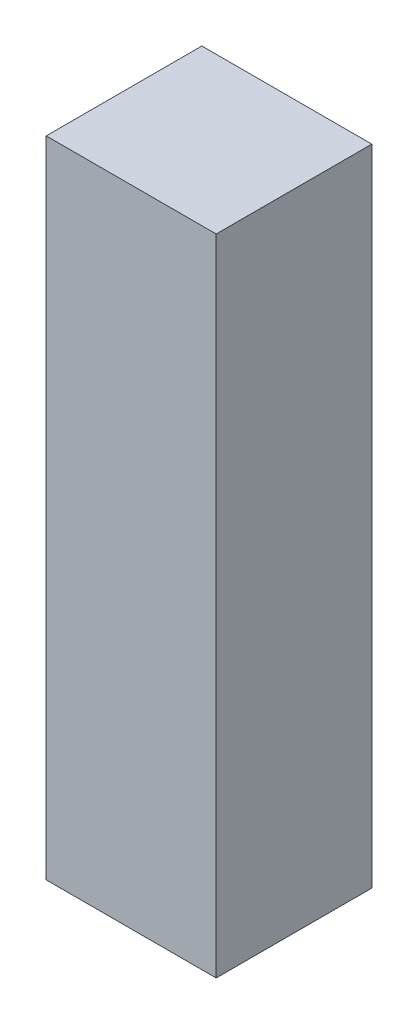
from build123d import *

# Parameters (mm, degrees)
SKETCH1_W           = 27.3
SKETCH1_H           = 25
BOSS_EXTRUDE1_DEPTH = 103.5


with BuildPart() as part:
    # Sketch1 → Boss-Extrude1 (new body)
    with BuildSketch(Plane(origin=(0, 0, 0), x_dir=(1, 0, 0), z_dir=(0, 1, 0))):
        Rectangle(SKETCH1_W, SKETCH1_H)
    extrude(amount=BOSS_EXTRUDE1_DEPTH)


solid = part.part
